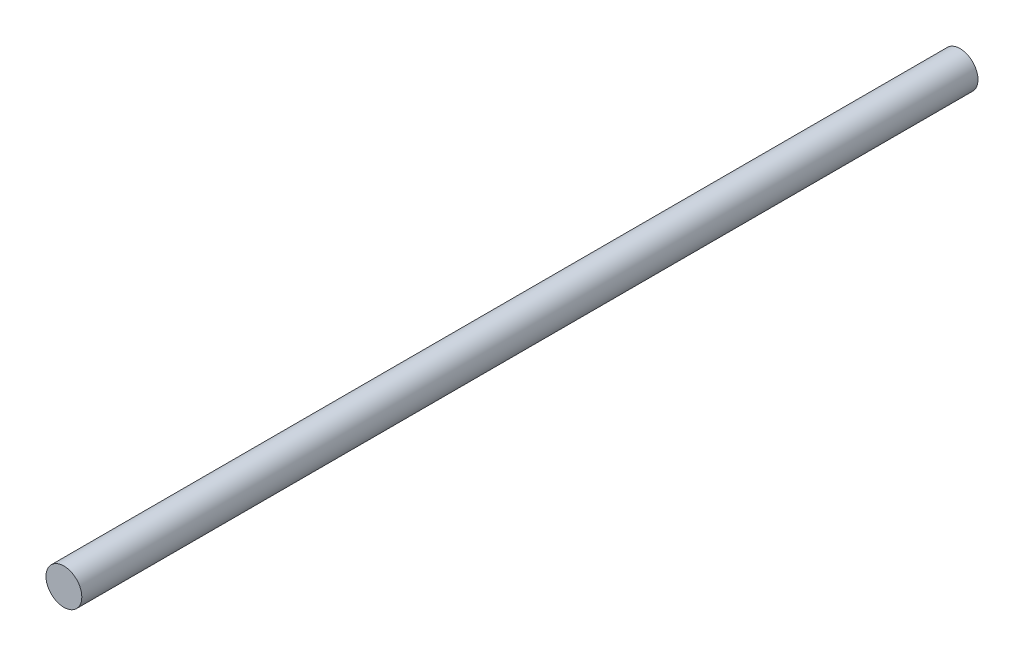
from build123d import *

# Parameters (mm, degrees)
CROQUIS1_R              = 6
SALIENTE_EXTRUIR1_DEPTH = 300


with BuildPart() as part:
    # Croquis1 → Saliente-Extruir1 (new body)
    with BuildSketch(Plane.XY):
        Circle(CROQUIS1_R)
    extrude(amount=SALIENTE_EXTRUIR1_DEPTH)


solid = part.part
